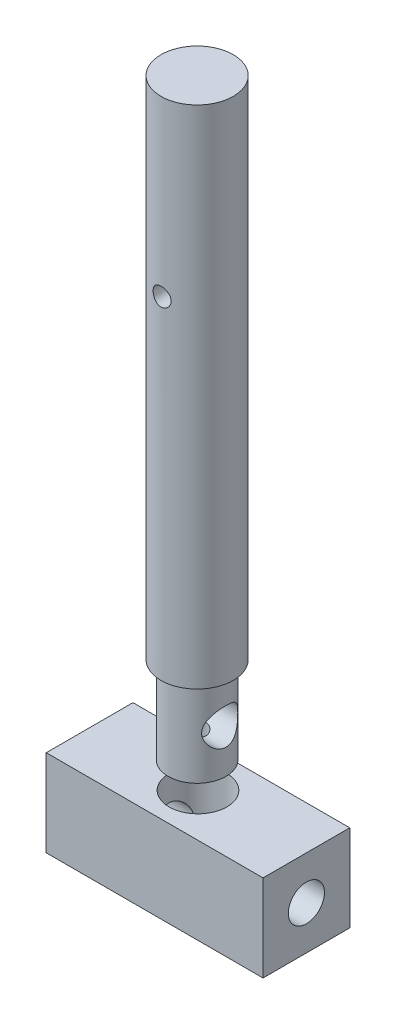
from build123d import *

# Parameters (mm, degrees)
ESQUISSE5_R                  = 4
BOSS_EXTRU_3_DEPTH           = 12
ESQUISSE6_R                  = 5
BOSS_EXTRU_4_DEPTH           = 70
ESQUISSE7_R                  = 2.5
ENL_V_MAT_EXTRU_3_DEPTH      = 10
ENL_V_MAT_EXTRU_3_DEPTH_BACK = 10
ESQUISSE8_R                  = 1.25
ENL_V_MAT_EXTRU_4_DEPTH      = 4
ESQUISSE9_W                  = 12
ESQUISSE9_H                  = 12
ESQUISSE9_R                  = 2.5
BOSS_EXTRU_5_DEPTH           = 15
BOSS_EXTRU_5_DEPTH_BACK      = 15
ESQUISSE10_R                 = 4
ENL_V_MAT_EXTRU_5_DEPTH      = 15
ESQUISSE11_R                 = 1.25
ENL_V_MAT_EXTRU_6_DEPTH      = 10
ENL_V_MAT_EXTRU_6_DEPTH_BACK = 10


with BuildPart() as part:
    # Esquisse5 → Boss.-Extru.3 (new body)
    with BuildSketch(Plane(origin=(0, 0, 0), x_dir=(1, 0, 0), z_dir=(0, 1, 0))):
        with Locations(Location((76.688805558, 0, 0), (0, 0, 270))):  # turned: the seam where the file's is
            Circle(ESQUISSE5_R)
    extrude(amount=-BOSS_EXTRU_3_DEPTH)

    # Esquisse6 → Boss.-Extru.4 (add)
    with BuildSketch(Plane(origin=(0, 0, 0), x_dir=(1, 0, 0), z_dir=(0, 1, 0))):
        with Locations(Location((76.688805558, 0, 0), (0, 0, 270))):  # turned: the seam where the file's is
            Circle(ESQUISSE6_R)
    extrude(amount=BOSS_EXTRU_4_DEPTH)

    # Esquisse7 → Enl_v. mat.-Extru.3 (cut, two sides)
    with BuildSketch(Plane(origin=(76.688805558, 0, 0), x_dir=(0, 0, -1), z_dir=(1, 0, 0))) as enl_v_mat_extru_3_sk:
        with Locations((0, -6)):
            Circle(ESQUISSE7_R)
    extrude(amount=ENL_V_MAT_EXTRU_3_DEPTH, mode=Mode.SUBTRACT)
    extrude(enl_v_mat_extru_3_sk.sketch, amount=-ENL_V_MAT_EXTRU_3_DEPTH_BACK, mode=Mode.SUBTRACT)

    # Esquisse8 → Enl_v. mat.-Extru.4 (cut)
    with BuildSketch(Plane.XZ.offset(12)):
        with Locations(Location((76.688805558, 0, 0), (0, 0, 270))):  # turned: the seam where the file's is
            Circle(ESQUISSE8_R)
    extrude(amount=-ENL_V_MAT_EXTRU_4_DEPTH, mode=Mode.SUBTRACT)

    # Esquisse11 → Enl_v. mat.-Extru.6 (cut, two sides)
    with BuildSketch(Plane.XY) as enl_v_mat_extru_6_sk:
        with Locations(Location((76.688805558, 46, 0), (0, 0, 89.999999996))):  # turned: the seam where the file's is
            Circle(ESQUISSE11_R)
    extrude(amount=ENL_V_MAT_EXTRU_6_DEPTH, mode=Mode.SUBTRACT)
    extrude(enl_v_mat_extru_6_sk.sketch, amount=-ENL_V_MAT_EXTRU_6_DEPTH_BACK, mode=Mode.SUBTRACT)


with BuildPart() as body_2:
    # Esquisse9 → Boss.-Extru.5 (new body, two sides)
    with BuildSketch(Plane(origin=(76.688805558, 0, 0), x_dir=(0, 0, -1), z_dir=(1, 0, 0))) as boss_extru_5_sk:
        with Locations((0.121410783, -21.719272195)):
            Rectangle(ESQUISSE9_W, ESQUISSE9_H)
        with Locations((0.121410783, -21.719272195)):
            Circle(ESQUISSE9_R, mode=Mode.SUBTRACT)
    extrude(amount=BOSS_EXTRU_5_DEPTH)
    extrude(boss_extru_5_sk.sketch, amount=-BOSS_EXTRU_5_DEPTH_BACK)

    # Esquisse10 → Enl_v. mat.-Extru.5 (cut)
    with BuildSketch(Plane(origin=(0, -15.719272195, 0), x_dir=(1, 0, 0), z_dir=(0, 1, 0))):
        with Locations(Location((76.688805558, 0.121410783, 0), (0, 0, 270))):  # turned: the seam where the file's is
            Circle(ESQUISSE10_R)
    extrude(amount=-ENL_V_MAT_EXTRU_5_DEPTH, mode=Mode.SUBTRACT)


solid = Compound([part.part, body_2.part])
